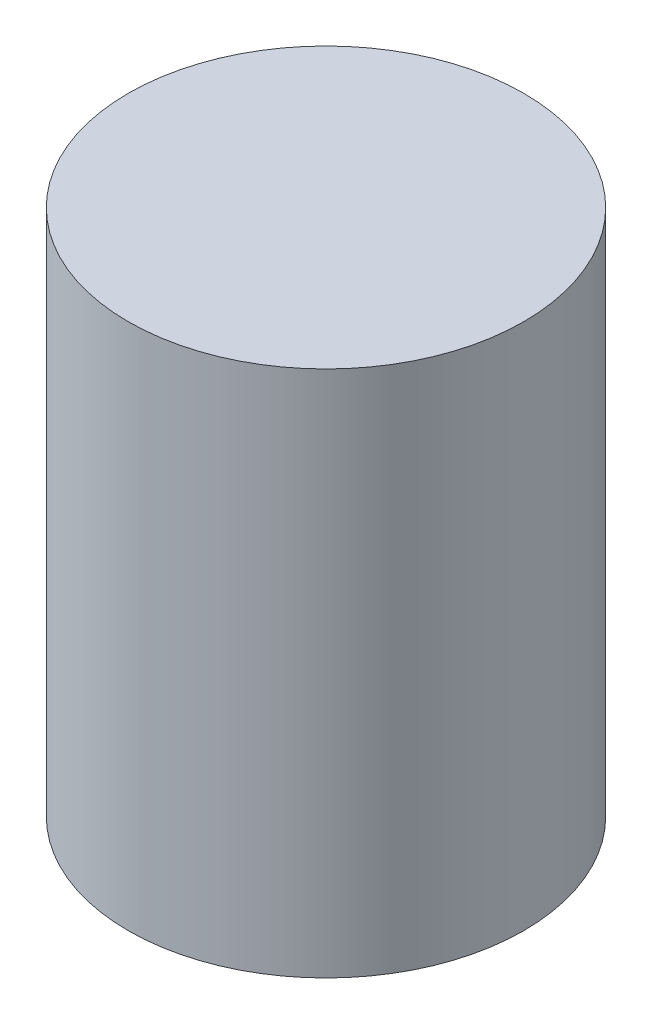
from build123d import *

# Parameters (mm, degrees)
SKETCH1_R           = 7.5
BOSS_EXTRUDE1_DEPTH = 20


with BuildPart() as part:
    # Sketch1 → Boss-Extrude1 (new body)
    with BuildSketch(Plane(origin=(0, 0, 0), x_dir=(1, 0, 0), z_dir=(0, 1, 0))):
        Circle(SKETCH1_R)
    extrude(amount=BOSS_EXTRUDE1_DEPTH)


solid = part.part
